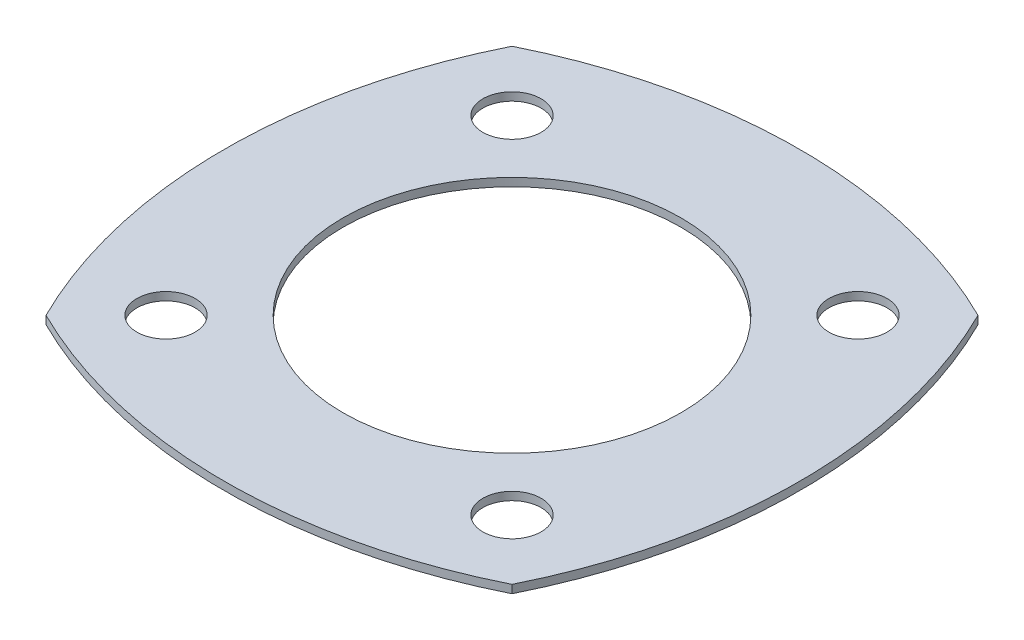
from build123d import *

# Parameters (mm, degrees)
SKETCH1_R           = 7.25
SKETCH1_R_2         = 1.25
BOSS_EXTRUDE1_DEPTH = 0.35


with BuildPart() as part:
    # Sketch1 → Boss-Extrude1 (new body)
    with BuildSketch(Plane(origin=(0, 0, 0), x_dir=(1, 0, 0), z_dir=(0, 1, 0))):
        with BuildLine():
            ThreePointArc((10, -10), (12.344355629, 0), (10, 10))
            ThreePointArc((10, 10), (0, 12.344355629), (-10, 10))
            ThreePointArc((-10, 10), (-12.344355629, 0), (-10, -10))
            ThreePointArc((-10, -10), (0, -12.344355629), (10, -10))
        make_face()
        Circle(SKETCH1_R, mode=Mode.SUBTRACT)
        with Locations((7.424621202, 7.424621202)):
            Circle(SKETCH1_R_2, mode=Mode.SUBTRACT)
        with Locations((7.424621202, -7.424621202)):
            Circle(SKETCH1_R_2, mode=Mode.SUBTRACT)
        with Locations((-7.424621202, -7.424621202)):
            Circle(SKETCH1_R_2, mode=Mode.SUBTRACT)
        with Locations((-7.424621202, 7.424621202)):
            Circle(SKETCH1_R_2, mode=Mode.SUBTRACT)
    extrude(amount=BOSS_EXTRUDE1_DEPTH)


solid = part.part
